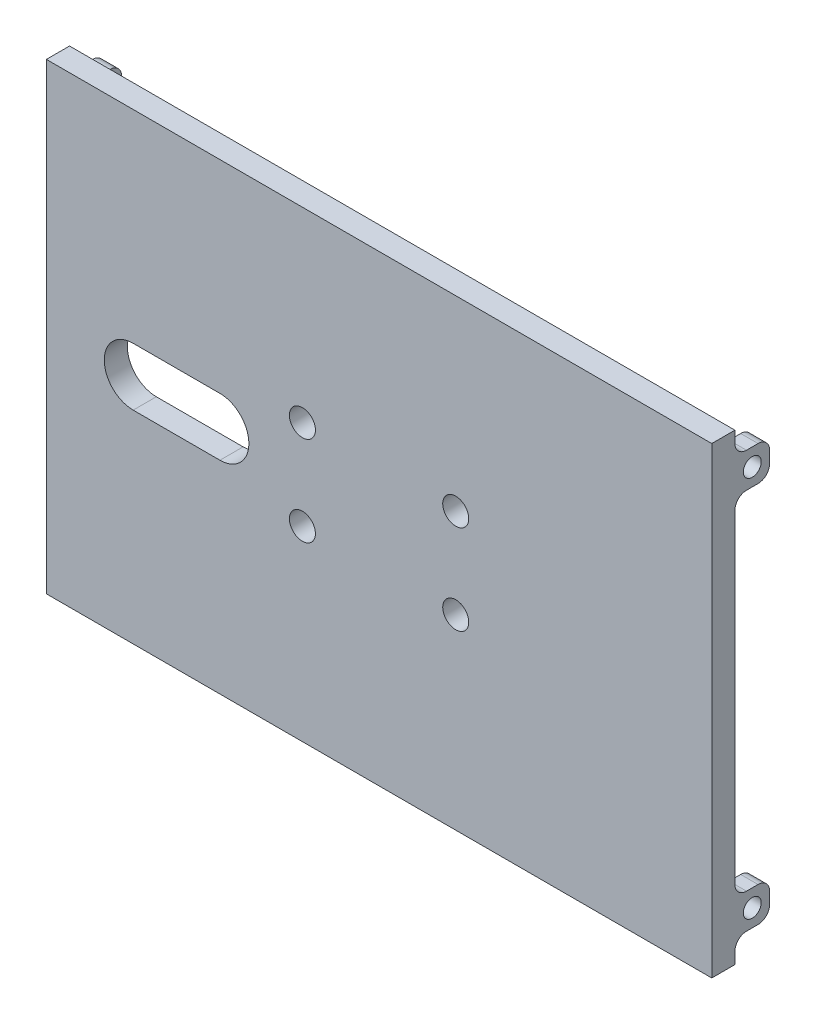
from build123d import *

# Parameters (mm, degrees)
SKETCH1_W               = 80
SKETCH1_H               = 115
BOSS_EXTRUDE1_DEPTH     = 4
CUT_EXTRUDE1_REACH      = 6
SKETCH2_R               = 2.25
SKETCH4_W               = 3
SKETCH4_H               = 6
BOSS_EXTRUDE3_DEPTH     = 6
SKETCH5_R               = 1.55
CUT_EXTRUDE2_DEPTH      = 1
CUT_EXTRUDE2_DEPTH_BACK = 116
FILLET1_R               = 2
CUT_EXTRUDE3_REACH      = 6


with BuildPart() as part:
    # Sketch1 → Boss-Extrude1 (new body)
    with BuildSketch(Plane(origin=(0, 0, 0), x_dir=(0, 1, 0), z_dir=(0, 0, 1))):
        Rectangle(SKETCH1_W, SKETCH1_H)
    extrude(amount=BOSS_EXTRUDE1_DEPTH)

    # Sketch2 → Cut-Extrude1 (cut, up to next)
    with BuildSketch(Plane.XY.offset(4), mode=Mode.PRIVATE) as cut_extrude1_sk1:
        with Locations((13.25, 7.75)):
            Circle(SKETCH2_R)
    cut_extrude1_tool1 = extrude(cut_extrude1_sk1.sketch, amount=-CUT_EXTRUDE1_REACH, mode=Mode.PRIVATE) & part.part
    add(cut_extrude1_tool1.solids().sort_by_distance((13.25, 7.75, 4))[0], mode=Mode.SUBTRACT)
    # Sketch2 → Cut-Extrude1 (cut, up to next)
    with BuildSketch(Plane.XY.offset(4), mode=Mode.PRIVATE) as cut_extrude1_sk2:
        with Locations((-13.25, 7.75)):
            Circle(SKETCH2_R)
    cut_extrude1_tool2 = extrude(cut_extrude1_sk2.sketch, amount=-CUT_EXTRUDE1_REACH, mode=Mode.PRIVATE) & part.part
    add(cut_extrude1_tool2.solids().sort_by_distance((-13.25, 7.75, 4))[0], mode=Mode.SUBTRACT)
    # Sketch2 → Cut-Extrude1 (cut, up to next)
    with BuildSketch(Plane.XY.offset(4), mode=Mode.PRIVATE) as cut_extrude1_sk3:
        with Locations((13.25, -7.75)):
            Circle(SKETCH2_R)
    cut_extrude1_tool3 = extrude(cut_extrude1_sk3.sketch, amount=-CUT_EXTRUDE1_REACH, mode=Mode.PRIVATE) & part.part
    add(cut_extrude1_tool3.solids().sort_by_distance((13.25, -7.75, 4))[0], mode=Mode.SUBTRACT)
    # Sketch2 → Cut-Extrude1 (cut, up to next)
    with BuildSketch(Plane.XY.offset(4), mode=Mode.PRIVATE) as cut_extrude1_sk4:
        with Locations((-13.25, -7.75)):
            Circle(SKETCH2_R)
    cut_extrude1_tool4 = extrude(cut_extrude1_sk4.sketch, amount=-CUT_EXTRUDE1_REACH, mode=Mode.PRIVATE) & part.part
    add(cut_extrude1_tool4.solids().sort_by_distance((-13.25, -7.75, 4))[0], mode=Mode.SUBTRACT)

    # Sketch4 → Boss-Extrude3 (add)
    with BuildSketch(Plane(origin=(0, 0, 0), x_dir=(1, 0, 0), z_dir=(0, 0, -1))):
        with Locations((-56, 33)):
            Rectangle(SKETCH4_W, SKETCH4_H)
        with Locations((56, 33)):
            Rectangle(SKETCH4_W, SKETCH4_H)
        with Locations((-56, -33)):
            Rectangle(SKETCH4_W, SKETCH4_H)
        with Locations((56, -33)):
            Rectangle(SKETCH4_W, SKETCH4_H)
    extrude(amount=BOSS_EXTRUDE3_DEPTH)

    # Sketch5 → Cut-Extrude2 (cut, two sides)
    with BuildSketch(Plane.YZ.offset(57.5)) as cut_extrude2_sk:
        with Locations((-33, -3)):
            Circle(SKETCH5_R)
        with Locations((33, -3)):
            Circle(SKETCH5_R)
    extrude(amount=CUT_EXTRUDE2_DEPTH, mode=Mode.SUBTRACT)
    extrude(cut_extrude2_sk.sketch, amount=-CUT_EXTRUDE2_DEPTH_BACK, mode=Mode.SUBTRACT)

    # Fillet1
    fillet1_edges = [part.edges().sort_by_distance(p)[0] for p in [
        (56, 30, 0),
        (56, 36, 0),
        (56, 30, -6),
        (56, 36, -6),
        (-56, 30, 0),
        (-56, 36, 0),
        (-56, 30, -6),
        (-56, 36, -6),
        (-56, -30, 0),
        (-56, -36, 0),
        (-56, -30, -6),
        (-56, -36, -6),
        (56, -36, 0),
        (56, -30, 0),
        (56, -36, -6),
        (56, -30, -6),
    ]]
    fillet(fillet1_edges, radius=FILLET1_R)

    # Sketch6 → Cut-Extrude3 (cut, up to next)
    with BuildSketch(Plane(origin=(0, 0, 0), x_dir=(1, 0, 0), z_dir=(0, 0, -1)), mode=Mode.PRIVATE) as cut_extrude3_sk1:
        with BuildLine():
            Line((-42.5, 5), (-27.5, 5))
            ThreePointArc((-27.5, 5), (-22.5, 0), (-27.5, -5))
            Line((-27.5, -5), (-42.5, -5))
            ThreePointArc((-42.5, -5), (-47.5, 0), (-42.5, 5))
        make_face()
    cut_extrude3_tool1 = extrude(cut_extrude3_sk1.sketch, amount=-CUT_EXTRUDE3_REACH, mode=Mode.PRIVATE) & part.part
    add(cut_extrude3_tool1.solids().sort_by_distance((-35, 0, 0))[0], mode=Mode.SUBTRACT)


solid = part.part
